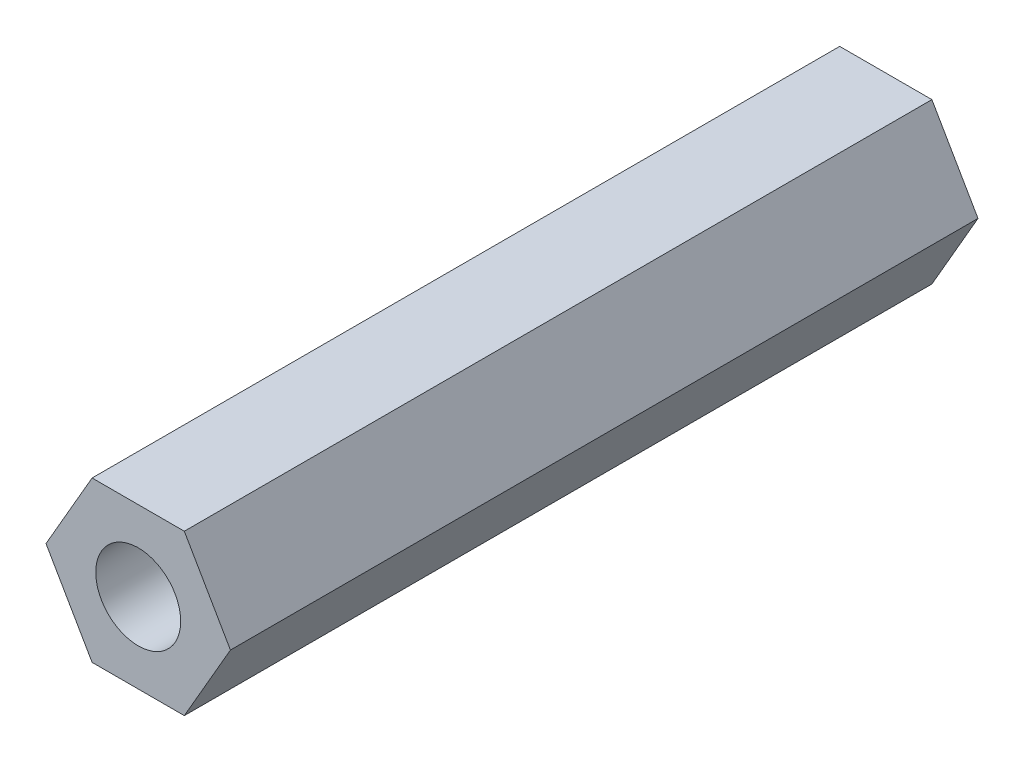
from build123d import *

# Parameters (mm, degrees)
EXTRUDE_1_DEPTH    = 11
HOLE_WIZARD_M3_1_D = 2.5


with BuildPart() as part:
    # 草图1 → 凸台-拉伸1 (new body, symmetric)
    with BuildSketch(Plane.XY):
        Polygon((1.356773133, 2.35), (-1.356773133, 2.35), (-2.713546265, 0), (-1.356773133, -2.35), (1.356773133, -2.35), (2.713546265, 0), align=None)
    extrude(amount=EXTRUDE_1_DEPTH, both=True)

    # M3 螺纹孔1 (through all)
    with Locations(Plane.XY.offset(11)):
        with Locations((0, 0)):
            Hole(HOLE_WIZARD_M3_1_D / 2)


solid = part.part
